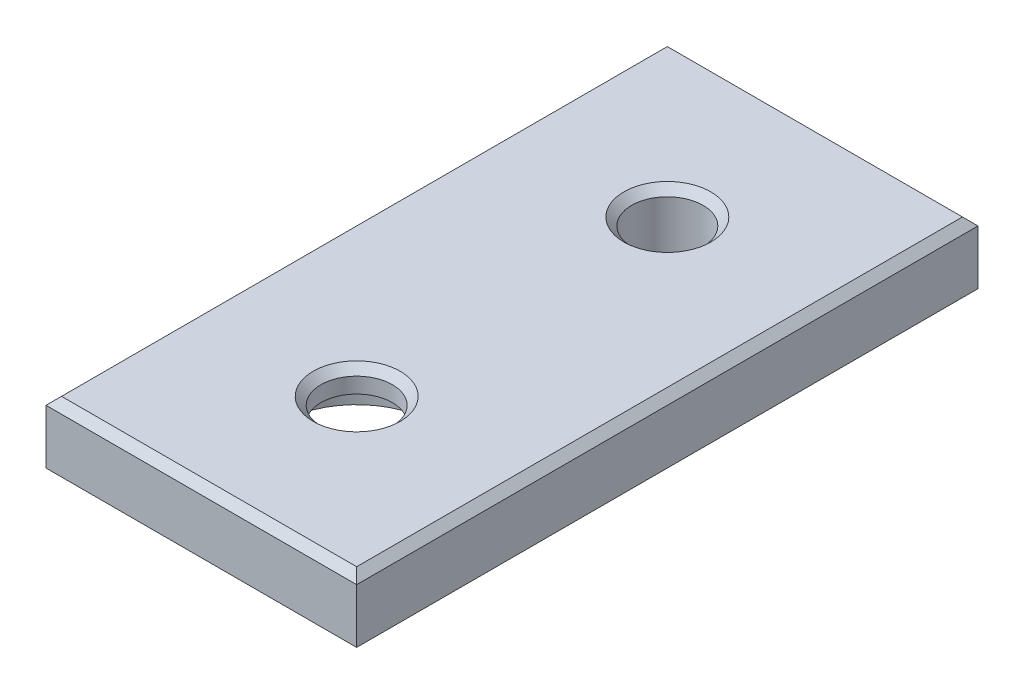
from build123d import *

# Parameters (mm, degrees)
ESBO_O1_W                  = 20
ESBO_O1_H                  = 40
RESSALTO_EXTRUS_O1_DEPTH   = 4
ESBO_O2_R                  = 2.3
CORTE_EXTRUS_O1_DEPTH      = 1
CORTE_EXTRUS_O1_DEPTH_BACK = 5
ESBO_O3_W                  = 5.9
ESBO_O3_H                  = 6
ESBO_O3_H_2                = 7
RESSALTO_EXTRUS_O2_DEPTH   = 2
CHANFRO1_SIZE              = 0.5
ESBO_O4_R                  = 5
CORTE_EXTRUS_O2_DEPTH      = 2.5


with BuildPart() as part:
    # Esboço1 → Ressalto-extrusão1 (new body)
    with BuildSketch(Plane(origin=(0, 0, 0), x_dir=(1, 0, 0), z_dir=(0, 1, 0))):
        Rectangle(ESBO_O1_W, ESBO_O1_H)
    extrude(amount=RESSALTO_EXTRUS_O1_DEPTH)

    # Esboço2 → Corte-extrusão1 (cut, two sides)
    with BuildSketch(Plane(origin=(0, 4, 0), x_dir=(1, 0, 0), z_dir=(0, 1, 0))) as corte_extrus_o1_sk:
        with Locations((0, 10)):
            Circle(ESBO_O2_R)
        with Locations((0, -10)):
            Circle(ESBO_O2_R)
    extrude(amount=CORTE_EXTRUS_O1_DEPTH, mode=Mode.SUBTRACT)
    extrude(corte_extrus_o1_sk.sketch, amount=-CORTE_EXTRUS_O1_DEPTH_BACK, mode=Mode.SUBTRACT)

    # Esboço3 → Ressalto-extrusão2 (add)
    with BuildSketch(Plane.XZ):
        with Locations((0, -4)):
            Rectangle(ESBO_O3_W, ESBO_O3_H)
        with Locations((0, -16.5)):
            Rectangle(ESBO_O3_W, ESBO_O3_H_2)
    extrude(amount=RESSALTO_EXTRUS_O2_DEPTH)

    # Chanfro1
    chanfro1_edges = [part.edges().sort_by_distance(p)[0] for p in [
        (-10, 4, 0),
        (0, 4, 20),
        (-2.3, 4, -10),
        (-2.3, 4, 10),
        (10, 4, 0),
        (0, 4, -20),
    ]]
    chamfer(chanfro1_edges, length=CHANFRO1_SIZE)

    # Esboço4 → Corte-extrusão2 (cut)
    with BuildSketch(Plane.XZ):
        with Locations((0, 10)):
            Circle(ESBO_O4_R)
    extrude(amount=-CORTE_EXTRUS_O2_DEPTH, mode=Mode.SUBTRACT)


solid = part.part
